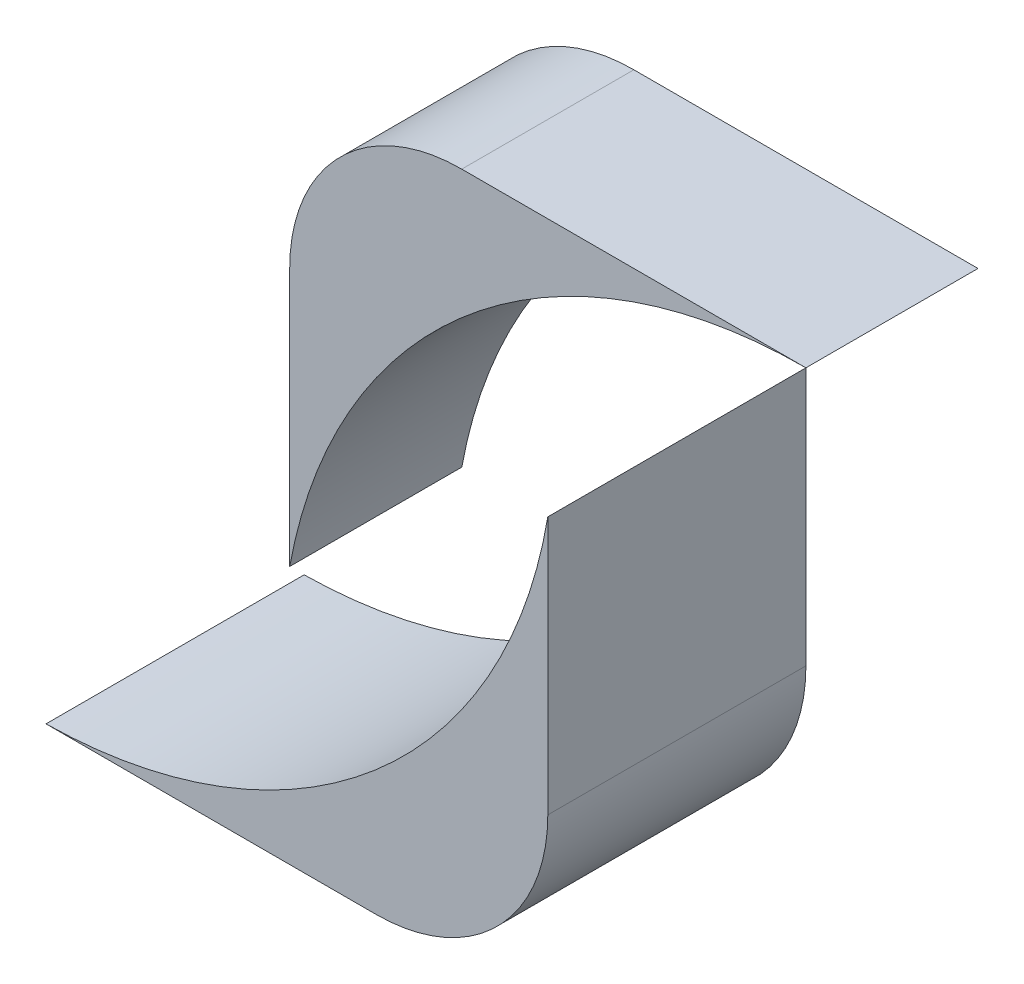
from build123d import *

# Parameters (mm, degrees)
BOSS_EXTRUDE3_DEPTH = 10
BOSS_EXTRUDE4_DEPTH = 15


with BuildPart() as part:
    # Sketch1 → Boss-Extrude3 (new body)
    with BuildSketch(Plane.XY):
        with BuildLine():
            Line((10, 25), (30, 25))
            ThreePointArc((30, 25), (10.47437581, 17.930749028), (0, 0))
            Line((0, 0), (0, 15))
            ThreePointArc((0, 15), (2.928932188, 22.071067812), (10, 25))
        make_face()
    extrude(amount=BOSS_EXTRUDE3_DEPTH)


with BuildPart() as body_2:
    # Sketch4 → Boss-Extrude4 (new body)
    with BuildSketch(Plane.XY.offset(10)):
        with BuildLine():
            ThreePointArc((30, 25), (19.944730561, 7.220988407), (0.838212742, 0))
            Line((0.838212742, 0), (20, 0))
            ThreePointArc((20, 0), (27.071067812, 2.928932188), (30, 10))
            Line((30, 10), (30, 25))
        make_face()
    extrude(amount=BOSS_EXTRUDE4_DEPTH)


solid = Compound([part.part, body_2.part])
